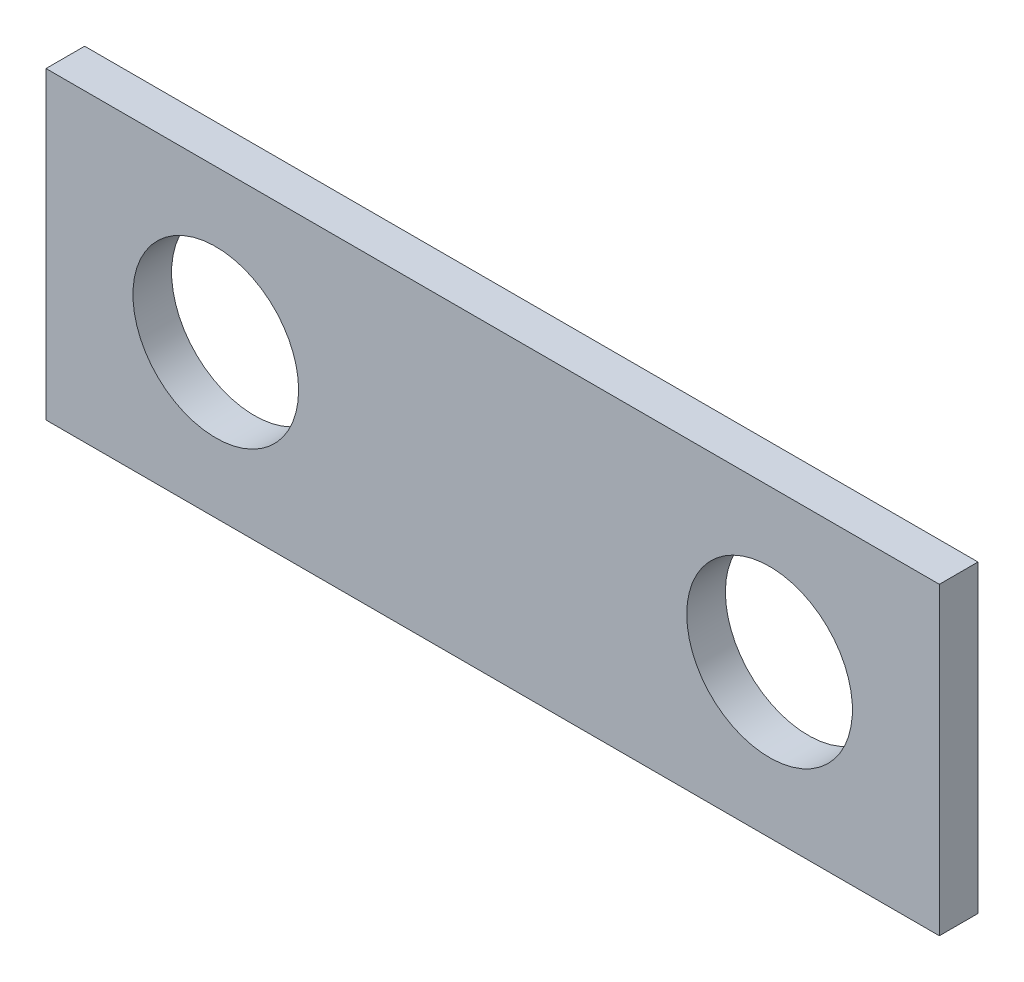
from build123d import *

# Parameters (mm, degrees)
SKETCH1_W           = 19.3802
SKETCH1_H           = 6.604
BOSS_EXTRUDE1_DEPTH = 0.8382
SKETCH2_R           = 1.79705
CUT_EXTRUDE1_DEPTH  = 0.8382


with BuildPart() as part:
    # Sketch1 → Boss-Extrude1 (new body)
    with BuildSketch(Plane.XY):
        with Locations((9.6901, 3.302)):
            Rectangle(SKETCH1_W, SKETCH1_H)
    extrude(amount=BOSS_EXTRUDE1_DEPTH)

    # Sketch2 → Cut-Extrude1 (cut)
    with BuildSketch(Plane.XY.offset(0.8382)):
        with Locations((3.683, 3.302)):
            Circle(SKETCH2_R)
        with Locations((15.6972, 3.302)):
            Circle(SKETCH2_R)
    extrude(amount=-CUT_EXTRUDE1_DEPTH, mode=Mode.SUBTRACT)


solid = part.part
